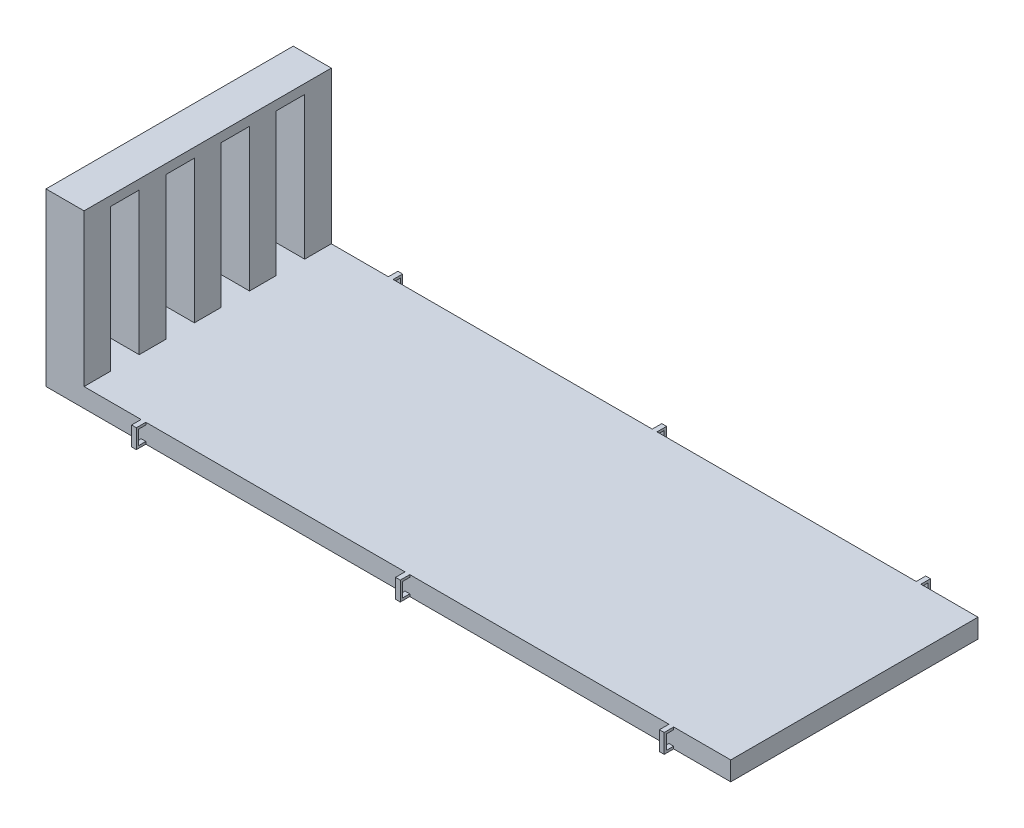
from build123d import *

# Parameters (mm, degrees)
SKETCH1_W           = 914.4
SKETCH1_H           = 330.2
BOSS_EXTRUDE1_DEPTH = 25.4
SKETCH2_W           = 50.8
SKETCH2_H           = 330.2
BOSS_EXTRUDE2_DEPTH = 203.2
SKETCH5_W           = 6.35
SKETCH5_H           = 25.4
BOSS_EXTRUDE3_DEPTH = 12.7
SKETCH6_W           = 9.525
SKETCH6_H           = 19.05
CUT_EXTRUDE1_DEPTH  = 6.35
SKETCH7_W           = 9.525
SKETCH7_H           = 19.05
CUT_EXTRUDE2_DEPTH  = 6.35
SKETCH8_W           = 9.51738
SKETCH8_H           = 19.05
CUT_EXTRUDE3_DEPTH  = 6.35
SKETCH9_W           = 6.35
SKETCH9_H           = 25.4
BOSS_EXTRUDE4_DEPTH = 12.7
SKETCH10_W          = 9.525
SKETCH10_H          = 19.05
CUT_EXTRUDE4_DEPTH  = 6.35
SKETCH11_W          = 9.525
SKETCH11_H          = 19.05
CUT_EXTRUDE5_DEPTH  = 6.35
SKETCH12_W          = 9.525
SKETCH12_H          = 19.05
CUT_EXTRUDE6_DEPTH  = 6.35
SKETCH15_W          = 38.1
SKETCH15_H          = 190.5
CUT_EXTRUDE7_DEPTH  = 51.8
SKETCH16_W          = 152.4
SKETCH16_H          = 101.6
BOSS_EXTRUDE5_DEPTH = 76.2


with BuildPart() as part:
    # Sketch1 → Boss-Extrude1 (new body)
    with BuildSketch(Plane(origin=(0, 0, 0), x_dir=(1, 0, 0), z_dir=(0, 1, 0))):
        with Locations((457.2, -165.1)):
            Rectangle(SKETCH1_W, SKETCH1_H)
    extrude(amount=BOSS_EXTRUDE1_DEPTH)

    # Sketch2 → Boss-Extrude2 (add)
    with BuildSketch(Plane(origin=(0, 25.4, 0), x_dir=(1, 0, 0), z_dir=(0, 1, 0))):
        with Locations((25.4, -165.1)):
            Rectangle(SKETCH2_W, SKETCH2_H)
    extrude(amount=BOSS_EXTRUDE2_DEPTH)

    # Sketch5 → Boss-Extrude3 (add)
    with BuildSketch(Plane.XY.offset(330.2)):
        with Locations((130.175, 12.7)):
            Rectangle(SKETCH5_W, SKETCH5_H)
        with Locations((482.6, 12.7)):
            Rectangle(SKETCH5_W, SKETCH5_H)
        with Locations((835.025, 12.7)):
            Rectangle(SKETCH5_W, SKETCH5_H)
    extrude(amount=BOSS_EXTRUDE3_DEPTH)

    # Sketch6 → Cut-Extrude1 (cut)
    with BuildSketch(Plane(origin=(133.35, 0, 0), x_dir=(0, 0, -1), z_dir=(1, 0, 0))):
        with Locations((-334.9625, 12.7)):
            Rectangle(SKETCH6_W, SKETCH6_H)
    extrude(amount=-CUT_EXTRUDE1_DEPTH, mode=Mode.SUBTRACT)

    # Sketch7 → Cut-Extrude2 (cut)
    with BuildSketch(Plane(origin=(485.775, 0, 0), x_dir=(0, 0, -1), z_dir=(1, 0, 0))):
        with Locations((-334.9625, 12.7)):
            Rectangle(SKETCH7_W, SKETCH7_H)
    extrude(amount=-CUT_EXTRUDE2_DEPTH, mode=Mode.SUBTRACT)

    # Sketch8 → Cut-Extrude3 (cut)
    with BuildSketch(Plane(origin=(838.2, 0, 0), x_dir=(0, 0, -1), z_dir=(1, 0, 0))):
        with Locations((-334.95869, 12.7)):
            Rectangle(SKETCH8_W, SKETCH8_H)
    extrude(amount=-CUT_EXTRUDE3_DEPTH, mode=Mode.SUBTRACT)

    # Sketch9 → Boss-Extrude4 (add)
    with BuildSketch(Plane(origin=(0, 0, 0), x_dir=(-1, 0, 0), z_dir=(0, 0, -1))):
        with Locations((-835.025, 12.7)):
            Rectangle(SKETCH9_W, SKETCH9_H)
        with Locations((-482.6, 12.7)):
            Rectangle(SKETCH9_W, SKETCH9_H)
        with Locations((-130.175, 12.7)):
            Rectangle(SKETCH9_W, SKETCH9_H)
    extrude(amount=BOSS_EXTRUDE4_DEPTH)

    # Sketch10 → Cut-Extrude4 (cut)
    with BuildSketch(Plane(origin=(133.35, 0, 0), x_dir=(0, 0, -1), z_dir=(1, 0, 0))):
        with Locations((4.7625, 12.7)):
            Rectangle(SKETCH10_W, SKETCH10_H)
    extrude(amount=-CUT_EXTRUDE4_DEPTH, mode=Mode.SUBTRACT)

    # Sketch11 → Cut-Extrude5 (cut)
    with BuildSketch(Plane(origin=(485.775, 0, 0), x_dir=(0, 0, -1), z_dir=(1, 0, 0))):
        with Locations((4.7625, 12.7)):
            Rectangle(SKETCH11_W, SKETCH11_H)
    extrude(amount=-CUT_EXTRUDE5_DEPTH, mode=Mode.SUBTRACT)

    # Sketch12 → Cut-Extrude6 (cut)
    with BuildSketch(Plane(origin=(838.2, 0, 0), x_dir=(0, 0, -1), z_dir=(1, 0, 0))):
        with Locations((4.7625, 12.7)):
            Rectangle(SKETCH12_W, SKETCH12_H)
    extrude(amount=-CUT_EXTRUDE6_DEPTH, mode=Mode.SUBTRACT)

    # Sketch15 → Cut-Extrude7 (cut, through all)
    with BuildSketch(Plane(origin=(50.8, 0, 0), x_dir=(0, 0, -1), z_dir=(1, 0, 0))):
        with Locations((-275.59, 120.65)):
            Rectangle(SKETCH15_W, SKETCH15_H)
        with Locations((-201.93, 120.65)):
            Rectangle(SKETCH15_W, SKETCH15_H)
        with Locations((-128.27, 120.65)):
            Rectangle(SKETCH15_W, SKETCH15_H)
        with Locations((-54.61, 120.65)):
            Rectangle(SKETCH15_W, SKETCH15_H)
    extrude(amount=-CUT_EXTRUDE7_DEPTH, mode=Mode.SUBTRACT)

    # Sketch16 → Boss-Extrude5 (add)
    with BuildSketch(Plane.XZ):
        with Locations((685.8, 165.1)):
            Rectangle(SKETCH16_W, SKETCH16_H)
    extrude(amount=BOSS_EXTRUDE5_DEPTH)


solid = part.part
